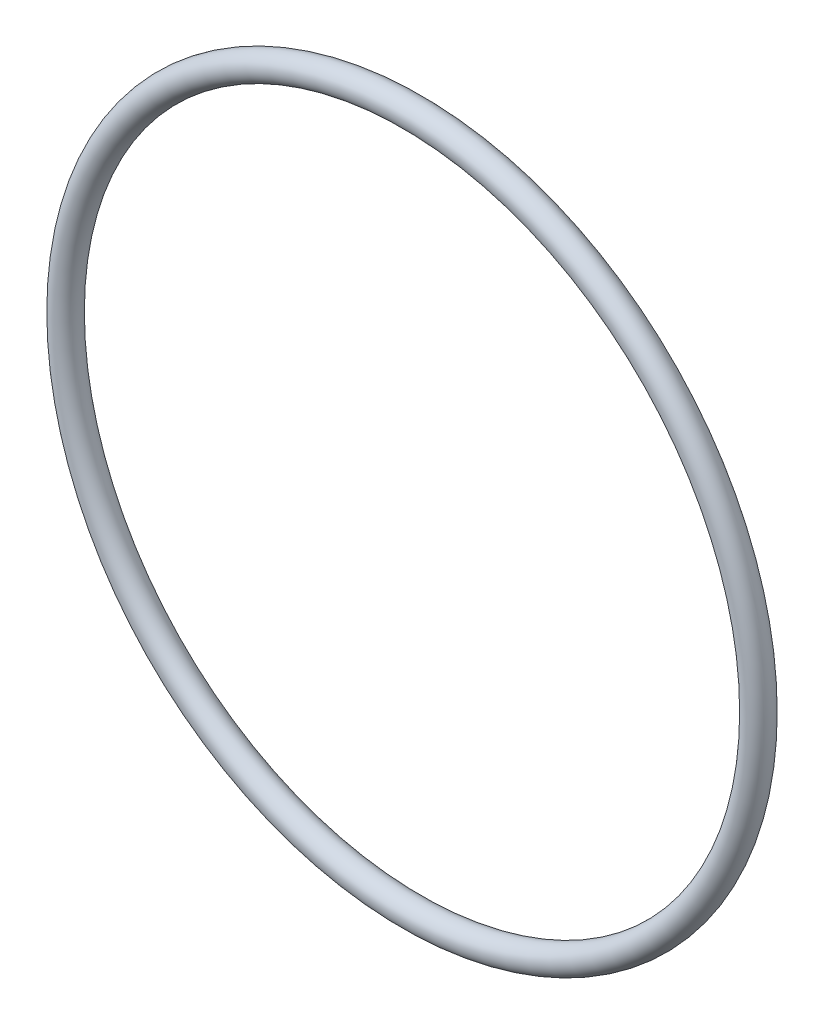
from build123d import *

# Parameters (mm, degrees)
SKETCH1_R = 1.7653


with BuildPart() as part:
    # Sketch1 → Revolve1 (revolve)
    with BuildSketch(Plane(origin=(0, 0, 0), x_dir=(0, -1, 0), z_dir=(1, 0, 0))):
        with Locations((46.0121, 0)):
            Circle(SKETCH1_R)
    revolve(axis=Axis((0, 0, 1.7653), (0, 0, -1)))


solid = part.part
